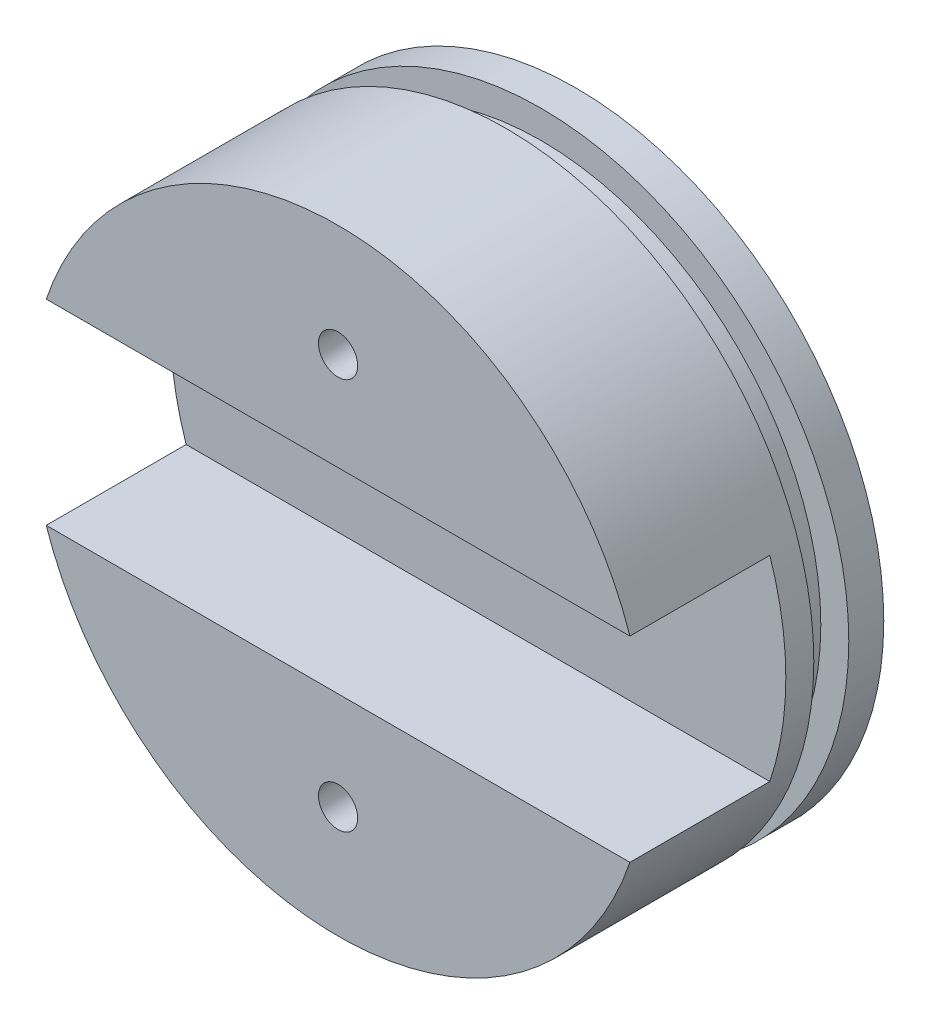
from build123d import *

# Parameters (mm, degrees)
SKETCH1_R           = 22
BOSS_EXTRUDE1_DEPTH = 2.5
SKETCH2_R           = 20
BOSS_EXTRUDE2_DEPTH = 5
BOSS_EXTRUDE3_START = 5
SKETCH1_2_R         = 22
BOSS_EXTRUDE3_DEPTH = 12
CUT_EXTRUDE1_START  = 17
SKETCH3_W           = 56.338981098
SKETCH3_H           = 14
CUT_EXTRUDE1_DEPTH  = 10
SKETCH4_R           = 1.4
CUT_EXTRUDE2_DEPTH  = 18
SKETCH5_R           = 3
CUT_EXTRUDE3_DEPTH  = 1.3


with BuildPart() as part:
    # Sketch1 → Boss-Extrude1 (new body)
    with BuildSketch(Plane.XY):
        Circle(SKETCH1_R)
    extrude(amount=BOSS_EXTRUDE1_DEPTH)

    # Sketch2 → Boss-Extrude2 (add)
    with BuildSketch(Plane.XY):
        Circle(SKETCH2_R)
    extrude(amount=BOSS_EXTRUDE2_DEPTH)

    # Sketch1_2 → Boss-Extrude3 (add)
    with BuildSketch(Plane.XY.offset(BOSS_EXTRUDE3_START)):
        Circle(SKETCH1_2_R)
    extrude(amount=BOSS_EXTRUDE3_DEPTH)

    # Sketch3 → Cut-Extrude1 (cut)
    with BuildSketch(Plane.XY.offset(CUT_EXTRUDE1_START)):
        with Locations((-1.268364496, 0)):
            Rectangle(SKETCH3_W, SKETCH3_H)
    extrude(amount=-CUT_EXTRUDE1_DEPTH, mode=Mode.SUBTRACT)

    # Sketch4 → Cut-Extrude2 (cut, through all)
    with BuildSketch(Plane.XY):
        with Locations((0, 14)):
            Circle(SKETCH4_R)
        with Locations((0, -14)):
            Circle(SKETCH4_R)
    extrude(amount=CUT_EXTRUDE2_DEPTH, mode=Mode.SUBTRACT)

    # Sketch5 → Cut-Extrude3 (cut)
    with BuildSketch(Plane.XY):
        with Locations((0, 14)):
            Circle(SKETCH5_R)
        with Locations((0, -14)):
            Circle(SKETCH5_R)
    extrude(amount=CUT_EXTRUDE3_DEPTH, mode=Mode.SUBTRACT)


solid = part.part
